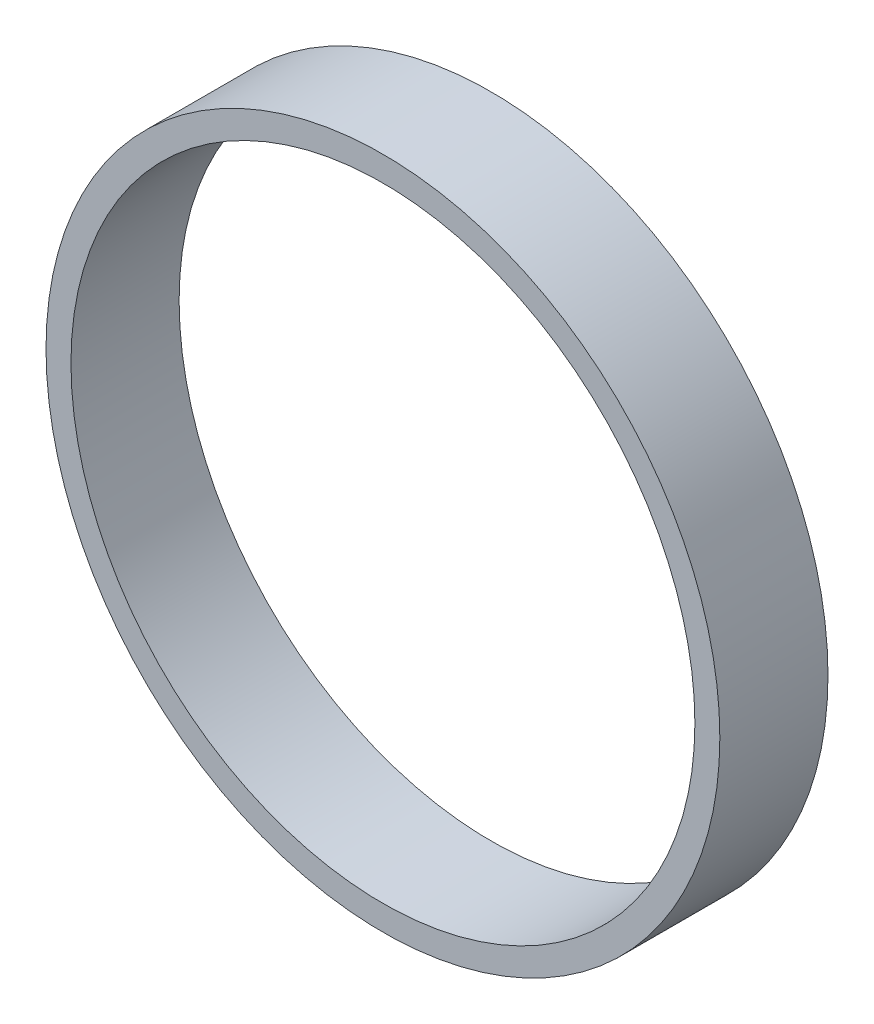
from build123d import *

# Parameters (mm, degrees)
SKETCH4_R           = 10.287
BOSS_EXTRUDE3_DEPTH = 3.302
SKETCH5_R           = 9.525
CUT_EXTRUDE2_DEPTH  = 4.302


with BuildPart() as part:
    # Sketch4 → Boss-Extrude3 (new body)
    with BuildSketch(Plane.XY):
        Circle(SKETCH4_R)
    extrude(amount=BOSS_EXTRUDE3_DEPTH)

    # Sketch5 → Cut-Extrude2 (cut, through all)
    with BuildSketch(Plane.XY.offset(3.302)):
        Circle(SKETCH5_R)
    extrude(amount=-CUT_EXTRUDE2_DEPTH, mode=Mode.SUBTRACT)


solid = part.part
